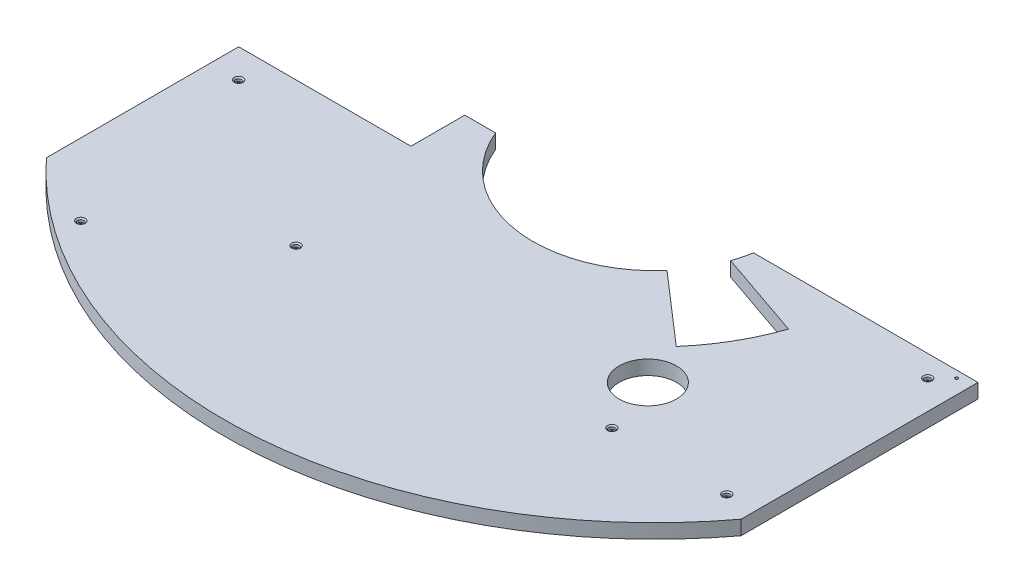
from build123d import *

# Parameters (mm, degrees)
SKETCH2_W                                     = 2006.6
SKETCH2_H                                     = 762
BOSS_EXTRUDE1_DEPTH                           = 25.4
CUT_EXTRUDE18_DEPTH                           = 26.4
F_1_4_20_TAPPED_HOLE1_D                       = 5.1054
SKETCH4_R                                     = 215.9
CUT_EXTRUDE1_DEPTH                            = 26.4
SKETCH26_W                                    = 381
SKETCH26_H                                    = 82.55
CUT_EXTRUDE2_DEPTH                            = 26.4
SKETCH109_R                                   = 50.8
CUT_EXTRUDE15_DEPTH                           = 26.4
SKETCH48_W                                    = 304.8
SKETCH48_H                                    = 95.25
CUT_EXTRUDE9_DEPTH                            = 26.4
CUT_EXTRUDE12_DEPTH                           = 26.4
CUT_EXTRUDE13_DEPTH                           = 26.4
CUT_EXTRUDE17_DEPTH                           = 26.4
CBORE_FOR_1_4_SOCKET_HEAD_CAP_SCREW1_AT_COUNT = 2
CBORE_FOR_1_4_SOCKET_HEAD_CAP_SCREW1_AT_PITCH = 558.8
CBORE_FOR_1_4_SOCKET_HEAD_CAP_SCREW1_2_COUNT  = 2
CBORE_FOR_1_4_SOCKET_HEAD_CAP_SCREW1_2_PITCH  = 366.324009587
CBORE_FOR_1_4_SOCKET_HEAD_CAP_SCREW1_3_COUNT  = 2
CBORE_FOR_1_4_SOCKET_HEAD_CAP_SCREW1_3_PITCH  = 274.74300719
CBORE_FOR_1_4_SOCKET_HEAD_CAP_SCREW1_4_COUNT  = 2
CBORE_FOR_1_4_SOCKET_HEAD_CAP_SCREW1_4_PITCH  = 840.889624148
CBORE_FOR_1_4_SOCKET_HEAD_CAP_SCREW1_5_COUNT  = 2
CBORE_FOR_1_4_SOCKET_HEAD_CAP_SCREW1_5_PITCH  = 762


with BuildPart() as part:
    # Sketch2 → Boss-Extrude1 (new body)
    with BuildSketch(Plane(origin=(0, 0, 0), x_dir=(1, 0, 0), z_dir=(0, 1, 0))):
        with Locations((596.720248579, 143.454782609)):
            Rectangle(SKETCH2_W, SKETCH2_H)
    extrude(amount=BOSS_EXTRUDE1_DEPTH)

    # Sketch120 → Cut-Extrude18 (cut, through all)
    with BuildSketch(Plane(origin=(0, 25.4, 0), x_dir=(1, 0, 0), z_dir=(0, 1, 0))):
        with BuildLine():
            Line((364.731895319, 486.354782609), (761.820248579, 486.354782609))
            Line((761.820248579, 486.354782609), (761.820248579, 524.454782609))
            Line((761.820248579, 524.454782609), (368.120248579, 524.454782609))
            ThreePointArc((368.120248579, 524.454782609), (367.271491927, 505.329596742), (364.731895319, 486.354782609))
        make_face()
    extrude(amount=-CUT_EXTRUDE18_DEPTH, mode=Mode.SUBTRACT)

    # 1/4-20 Tapped Hole1 (through all)
    with Locations(Plane(origin=(0, 25.4, 0), x_dir=(1, 0, 0), z_dir=(0, 1, 0))):
        with Locations((736.420248579, 473.948827926)):
            Hole(F_1_4_20_TAPPED_HOLE1_D / 2)

    # Sketch4 → Cut-Extrude1 (cut, through all)
    with BuildSketch(Plane(origin=(0, 25.4, 0), x_dir=(1, 0, 0), z_dir=(0, 1, 0))):
        with Locations((152.220248579, 524.454782609)):
            Circle(SKETCH4_R)
    extrude(amount=-CUT_EXTRUDE1_DEPTH, mode=Mode.SUBTRACT)

    # Sketch26 → Cut-Extrude2 (cut, through all)
    with BuildSketch(Plane(origin=(0, 25.4, 0), x_dir=(1, 0, 0), z_dir=(0, 1, 0))):
        with Locations((-216.079751421, 483.179782609)):
            Rectangle(SKETCH26_W, SKETCH26_H)
    extrude(amount=-CUT_EXTRUDE2_DEPTH, mode=Mode.SUBTRACT)

    # Sketch109 → Cut-Extrude15 (cut, through all)
    with BuildSketch(Plane(origin=(0, 25.4, 0), x_dir=(1, 0, 0), z_dir=(0, 1, 0))):
        with Locations((469.720248579, 194.254782609)):
            Circle(SKETCH109_R)
    extrude(amount=-CUT_EXTRUDE15_DEPTH, mode=Mode.SUBTRACT)

    # Sketch48 → Cut-Extrude9 (cut, through all)
    with BuildSketch(Plane(origin=(0, 25.4, 0), x_dir=(1, 0, 0), z_dir=(0, 1, 0))):
        with Locations((-254.179751421, 394.279782609)):
            Rectangle(SKETCH48_W, SKETCH48_H)
    extrude(amount=-CUT_EXTRUDE9_DEPTH, mode=Mode.SUBTRACT)

    # Sketch56 → Cut-Extrude12 (cut, through all)
    with BuildSketch(Plane(origin=(0, 25.4, 0), x_dir=(1, 0, 0), z_dir=(0, 1, 0))):
        with BuildLine():
            Line((512.462825882, 400.413315761), (152.220248579, 524.454782609))
            Line((152.220248579, 524.454782609), (439.764598644, 274.496292563))
            ThreePointArc((439.764598644, 274.496292563), (482.175927421, 333.954782609), (512.462825882, 400.413315761))
        make_face()
    extrude(amount=-CUT_EXTRUDE12_DEPTH, mode=Mode.SUBTRACT)

    # Sketch105 → Cut-Extrude13 (cut, through all)
    with BuildSketch(Plane(origin=(0, 25.4, 0), x_dir=(1, 0, 0), z_dir=(0, 1, 0))):
        with BuildLine():
            Line((152.220248579, -237.545217391), (-406.579751421, -237.545217391))
            Line((-406.579751421, -237.545217391), (-406.579751421, 6.394400028))
            ThreePointArc((-406.579751421, 6.394400028), (-152.64200595, -173.902579895), (152.220248579, -237.545217391))
        make_face()
    extrude(amount=-CUT_EXTRUDE13_DEPTH, mode=Mode.SUBTRACT)

    # Sketch111 → Cut-Extrude17 (cut, through all)
    with BuildSketch(Plane(origin=(0, 25.4, 0), x_dir=(1, 0, 0), z_dir=(0, 1, 0))):
        with BuildLine():
            Line((761.820248579, 67.254782609), (761.820248579, 524.454782609))
            Line((761.820248579, 524.454782609), (1600.020248579, 524.454782609))
            Line((1600.020248579, 524.454782609), (1600.020248579, -237.545217391))
            Line((1600.020248579, -237.545217391), (152.220248579, -237.545217391))
            ThreePointArc((152.220248579, -237.545217391), (492.99700835, -157.098736933), (761.820248579, 67.254782609))
        make_face()
    extrude(amount=-CUT_EXTRUDE17_DEPTH, mode=Mode.SUBTRACT)

    # Sketch123 → CBORE for 1/4 Socket Head Cap Screw1 (revolve, cut)
    with BuildSketch(Plane(origin=(-50.979751421, 25.4, -92.654782609), x_dir=(0, 0, 1), z_dir=(1, 0, 0))):
        Polygon((0, 0), (0, 25.4), (3.3782, 25.4), (3.3782, 6.35), (5.55625, 6.35), (5.55625, 2.2225), (7.77875, 0), align=None)
    cbore_for_1_4_socket_head_cap_screw1 = revolve(axis=Axis((-50.979751421, 31.75, -92.654782609), (0, -1, 0)), mode=Mode.SUBTRACT)

    # CBORE for 1/4 Socket Head Cap Screw1 at: CBORE for 1/4 Socket Head Cap Screw1 ×2
    with Locations(*[(i * CBORE_FOR_1_4_SOCKET_HEAD_CAP_SCREW1_AT_PITCH, 0, 0) for i in range(1, CBORE_FOR_1_4_SOCKET_HEAD_CAP_SCREW1_AT_COUNT)]):
        add(cbore_for_1_4_socket_head_cap_screw1, mode=Mode.SUBTRACT)

    # CBORE for 1_4 Socket Head Cap Screw1 2: CBORE for 1/4 Socket Head Cap Screw1 ×2
    with Locations(*[Vector(-0.832050294, 0, -0.554700196) * (i * CBORE_FOR_1_4_SOCKET_HEAD_CAP_SCREW1_2_PITCH) for i in range(1, CBORE_FOR_1_4_SOCKET_HEAD_CAP_SCREW1_2_COUNT)]):
        add(cbore_for_1_4_socket_head_cap_screw1, mode=Mode.SUBTRACT)

    # CBORE for 1_4 Socket Head Cap Screw1 3: CBORE for 1/4 Socket Head Cap Screw1 ×2
    with Locations(*[Vector(-0.832050294, 0, 0.554700196) * (i * CBORE_FOR_1_4_SOCKET_HEAD_CAP_SCREW1_3_PITCH) for i in range(1, CBORE_FOR_1_4_SOCKET_HEAD_CAP_SCREW1_3_COUNT)]):
        add(cbore_for_1_4_socket_head_cap_screw1, mode=Mode.SUBTRACT)

    # CBORE for 1_4 Socket Head Cap Screw1 4: CBORE for 1/4 Socket Head Cap Screw1 ×2
    with Locations(*[Vector(0.90618314, 0, -0.422885465) * (i * CBORE_FOR_1_4_SOCKET_HEAD_CAP_SCREW1_4_PITCH) for i in range(1, CBORE_FOR_1_4_SOCKET_HEAD_CAP_SCREW1_4_COUNT)]):
        add(cbore_for_1_4_socket_head_cap_screw1, mode=Mode.SUBTRACT)

    # CBORE for 1_4 Socket Head Cap Screw1 5: CBORE for 1/4 Socket Head Cap Screw1 ×2
    with Locations(*[(i * CBORE_FOR_1_4_SOCKET_HEAD_CAP_SCREW1_5_PITCH, 0, 0) for i in range(1, CBORE_FOR_1_4_SOCKET_HEAD_CAP_SCREW1_5_COUNT)]):
        add(cbore_for_1_4_socket_head_cap_screw1, mode=Mode.SUBTRACT)


solid = part.part
